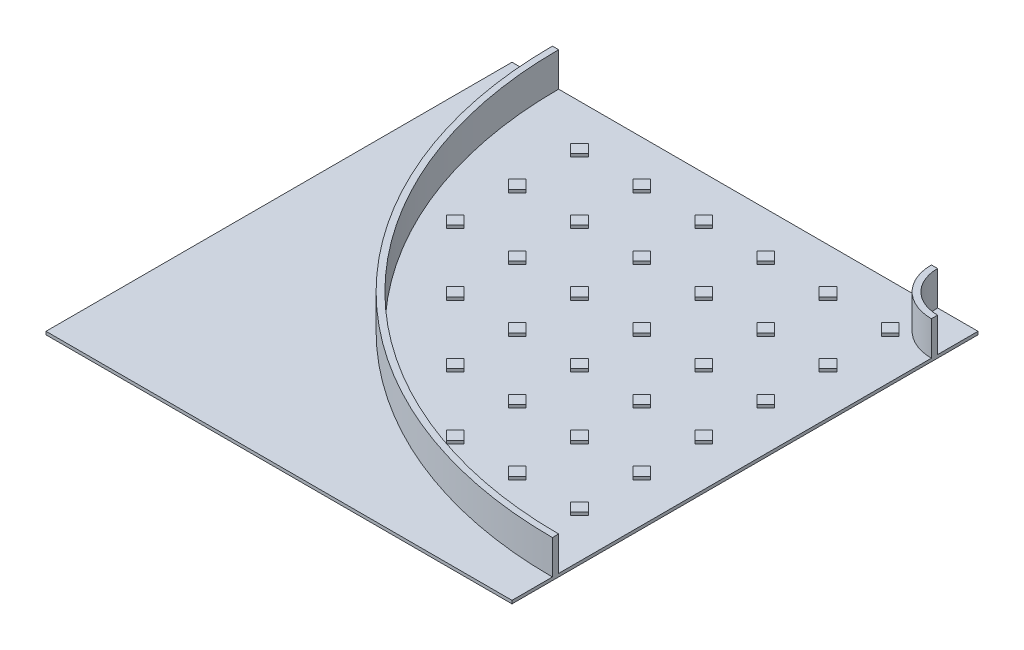
from build123d import *

# Parameters (mm, degrees)
SKETCH2_W           = 1500
SKETCH2_H           = 1500
BOSS_EXTRUDE1_DEPTH = 10
BOSS_EXTRUDE2_DEPTH = 110
BOSS_EXTRUDE3_DEPTH = 10


with BuildPart() as part:
    # Sketch2 → Boss-Extrude1 (new body)
    with BuildSketch(Plane(origin=(0, 0, 0), x_dir=(1, 0, 0), z_dir=(0, 1, 0))):
        Rectangle(SKETCH2_W, SKETCH2_H)
    extrude(amount=BOSS_EXTRUDE1_DEPTH)

    # Sketch3 → Boss-Extrude2 (add)
    with BuildSketch(Plane(origin=(0, 10, 0), x_dir=(1, 0, 0), z_dir=(0, 1, 0))):
        with BuildLine():
            ThreePointArc((750, -600), (-204.594154602, -204.594154602), (-600, 750))
            Line((-600, 750), (-620, 750))
            ThreePointArc((-620, 750), (-218.736290226, -218.736290226), (750, -620))
            Line((750, -620), (750, -600))
        make_face()
        with BuildLine():
            Line((620, 750), (600, 750))
            ThreePointArc((600, 750), (643.933982822, 643.933982822), (750, 600))
            Line((750, 600), (750, 620))
            ThreePointArc((750, 620), (658.076118446, 658.076118446), (620, 750))
        make_face()
    extrude(amount=BOSS_EXTRUDE2_DEPTH)

    # Sketch4 → Boss-Extrude3 (add)
    with BuildSketch(Plane(origin=(0, 10, 0), x_dir=(1, 0, 0), z_dir=(0, 1, 0))):
        Polygon((-391.421356236, 636.86291501), (-419.705627484, 608.578643763), (-391.421356236, 580.294372515), (-363.137084989, 608.578643763), align=None)
        Polygon((-191.421356236, 636.86291501), (-219.705627484, 608.578643763), (-191.421356236, 580.294372515), (-163.137084989, 608.578643763), align=None)
        Polygon((8.578643763, 636.86291501), (-19.705627484, 608.578643763), (8.578643763, 580.294372515), (36.862915011, 608.578643763), align=None)
        Polygon((208.578643763, 636.86291501), (180.294372516, 608.578643763), (208.578643763, 580.294372515), (236.862915011, 608.578643763), align=None)
        Polygon((408.578643763, 636.86291501), (380.294372515, 608.578643763), (408.578643763, 580.294372515), (436.86291501, 608.578643763), align=None)
        Polygon((-191.421356236, 436.86291501), (-219.705627484, 408.578643763), (-191.421356236, 380.294372515), (-163.137084989, 408.578643763), align=None)
        Polygon((8.578643763, 436.86291501), (-19.705627484, 408.578643763), (8.578643763, 380.294372515), (36.862915011, 408.578643763), align=None)
        Polygon((208.578643763, 436.86291501), (180.294372516, 408.578643763), (208.578643763, 380.294372515), (236.862915011, 408.578643763), align=None)
        Polygon((408.578643763, 436.86291501), (380.294372515, 408.578643763), (408.578643763, 380.294372515), (436.86291501, 408.578643763), align=None)
        Polygon((-191.421356236, 236.86291501), (-219.705627484, 208.578643763), (-191.421356236, 180.294372515), (-163.137084989, 208.578643763), align=None)
        Polygon((8.578643763, 236.86291501), (-19.705627484, 208.578643763), (8.578643763, 180.294372515), (36.862915011, 208.578643763), align=None)
        Polygon((208.578643763, 236.86291501), (180.294372516, 208.578643763), (208.578643763, 180.294372515), (236.862915011, 208.578643763), align=None)
        Polygon((408.578643763, 236.86291501), (380.294372515, 208.578643763), (408.578643763, 180.294372515), (436.86291501, 208.578643763), align=None)
        Polygon((-191.421356236, 36.86291501), (-219.705627484, 8.578643763), (-191.421356236, -19.705627485), (-163.137084989, 8.578643763), align=None)
        Polygon((8.578643763, 36.86291501), (-19.705627484, 8.578643763), (8.578643763, -19.705627485), (36.862915011, 8.578643763), align=None)
        Polygon((208.578643763, 36.86291501), (180.294372516, 8.578643763), (208.578643763, -19.705627485), (236.862915011, 8.578643763), align=None)
        Polygon((408.578643763, 36.86291501), (380.294372515, 8.578643763), (408.578643763, -19.705627485), (436.86291501, 8.578643763), align=None)
        Polygon((8.578643763, -163.13708499), (-19.705627484, -191.421356237), (8.578643763, -219.705627485), (36.862915011, -191.421356237), align=None)
        Polygon((208.578643763, -163.13708499), (180.294372516, -191.421356237), (208.578643763, -219.705627485), (236.862915011, -191.421356237), align=None)
        Polygon((408.578643763, -163.13708499), (380.294372515, -191.421356237), (408.578643763, -219.705627485), (436.86291501, -191.421356237), align=None)
        Polygon((-391.421356236, 436.86291501), (-419.705627484, 408.578643763), (-391.421356236, 380.294372515), (-363.137084989, 408.578643763), align=None)
        Polygon((-391.421356236, 236.86291501), (-419.705627484, 208.578643763), (-391.421356236, 180.294372515), (-363.137084989, 208.578643763), align=None)
        Polygon((208.578643763, -363.13708499), (180.294372516, -391.421356237), (208.578643763, -419.705627485), (236.862915011, -391.421356237), align=None)
        Polygon((408.578643763, -363.13708499), (380.294372515, -391.421356237), (408.578643763, -419.705627485), (436.86291501, -391.421356237), align=None)
        Polygon((608.578643763, 636.86291501), (580.294372515, 608.578643763), (608.578643763, 580.294372515), (636.86291501, 608.578643763), align=None)
        Polygon((608.578643763, 436.86291501), (580.294372515, 408.578643763), (608.578643763, 380.294372515), (636.86291501, 408.578643763), align=None)
        Polygon((608.578643763, 236.86291501), (580.294372515, 208.578643763), (608.578643763, 180.294372515), (636.86291501, 208.578643763), align=None)
        Polygon((608.578643763, 36.86291501), (580.294372515, 8.578643763), (608.578643763, -19.705627485), (636.86291501, 8.578643763), align=None)
        Polygon((608.578643763, -163.13708499), (580.294372515, -191.421356237), (608.578643763, -219.705627485), (636.86291501, -191.421356237), align=None)
        Polygon((608.578643763, -363.13708499), (580.294372515, -391.421356237), (608.578643763, -419.705627485), (636.86291501, -391.421356237), align=None)
    extrude(amount=BOSS_EXTRUDE3_DEPTH)


solid = part.part
